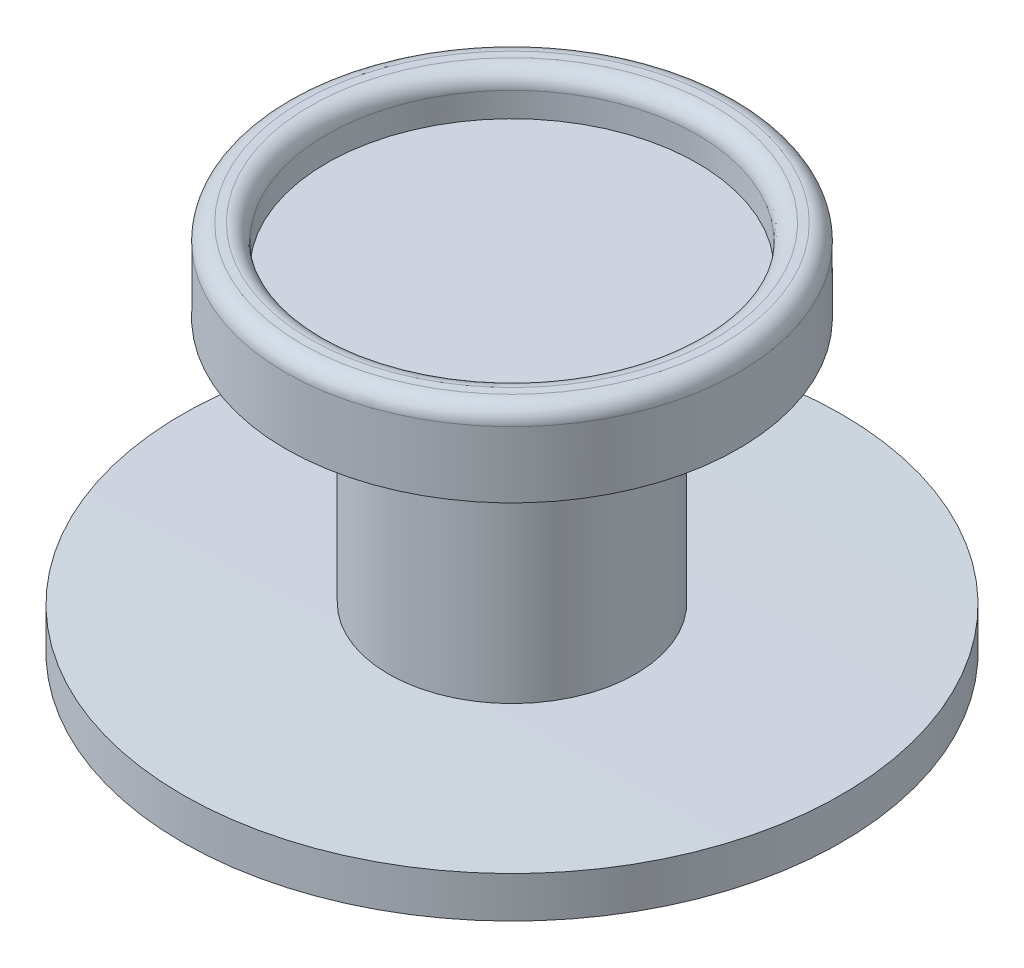
from build123d import *

# Parameters (mm, degrees)
CONG_1_R = 0.2


with BuildPart() as part:
    # Esquisse1 → Révolution1 (revolve)
    with BuildSketch(Plane.XY, mode=Mode.PRIVATE) as r_volution1_sk:
        with BuildLine():
            Line((-1.5, -1.002988992), (-1.5, -4.003013447))
            ThreePointArc((-1.5, -4.003013447), (-2.750015694, -4.010192747), (-4, -4.021595148))
            Line((-4, -4.021595148), (-4, -4.521595148))
            ThreePointArc((-4, -4.521595148), (-2.015564437, -4.896110644), (0, -5.021595148))
            Line((0, -5.021595148), (0, -0.50676811))
            Line((0, -0.50676811), (-2.25, -0.50676811))
            Line((-2.25, -0.50676811), (-2.25, -0.00676811))
            ThreePointArc((-2.25, -0.00676811), (-2.500000559, -0.008355713), (-2.75, -0.010110432))
            Line((-2.75, -0.010110432), (-2.75, -1.010110432))
            ThreePointArc((-2.75, -1.010110432), (-2.125002983, -1.006026077), (-1.5, -1.002988992))
        make_face()
    revolve(r_volution1_sk.sketch.rotate(Axis((0, 39.029541446, 0), (0, -1, 0)), 270), axis=Axis((0, 39.029541446, 0), (0, -1, 0)))  # turned: the seam where the file's is

    # Congé1
    cong_1_edges = [part.edges().sort_by_distance(p)[0] for p in [
        (0, -0.010110432, -2.75),
        (0, -0.00676811, -2.25),
    ]]
    fillet(cong_1_edges, radius=CONG_1_R)


solid = part.part
